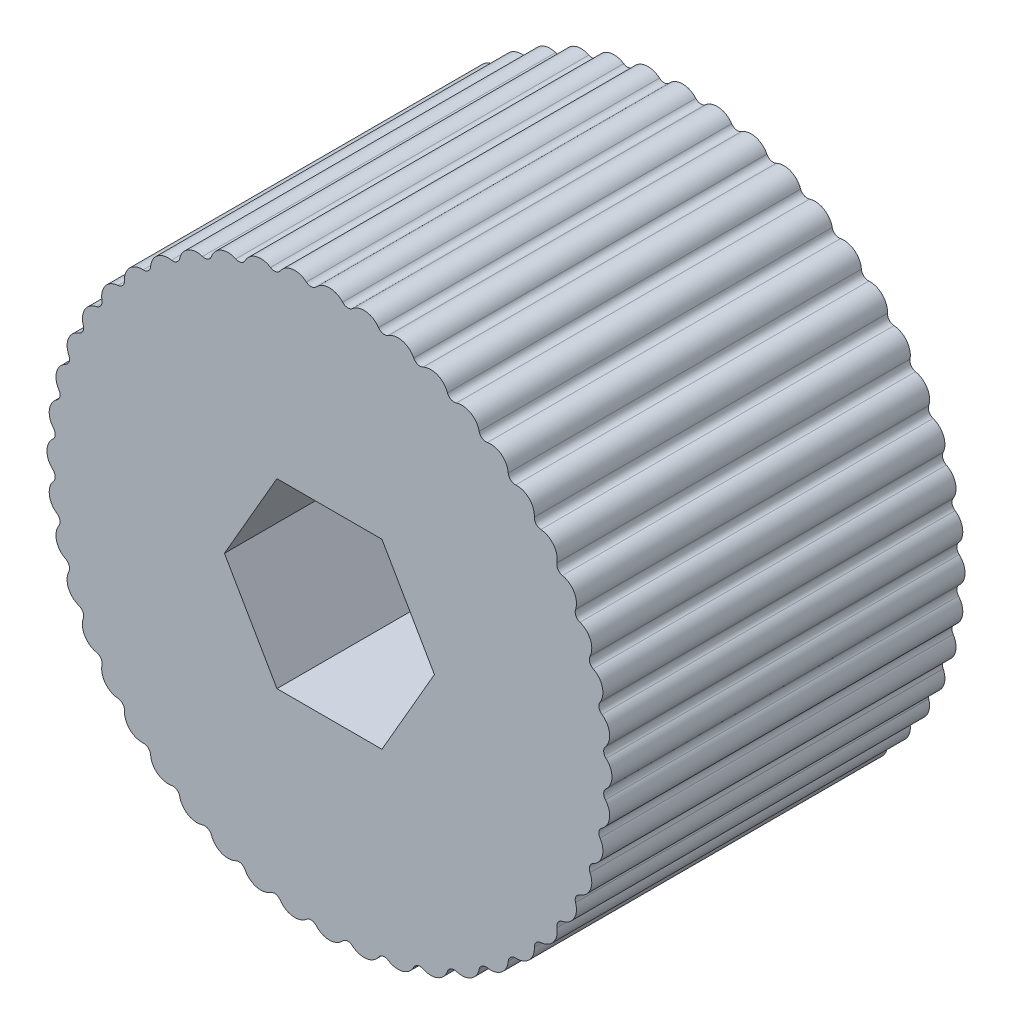
from build123d import *

# Parameters (mm, degrees)
SKETCH1_R           = 19.05
BOSS_EXTRUDE1_DEPTH = 25.4
BOSS_EXTRUDE2_DEPTH = 25.4
CIRPATTERN1_COUNT   = 48
FILLET1_R           = 0.508


with BuildPart() as part:
    # Sketch1 → Boss-Extrude1 (new body)
    with BuildSketch(Plane.XY):
        Circle(SKETCH1_R)
        Polygon((3.776159436, 6.5405), (-3.776159436, 6.5405), (-7.552318871, 0), (-3.776159436, -6.5405), (3.776159436, -6.5405), (7.552318871, 0), align=None, mode=Mode.SUBTRACT)
    extrude(amount=BOSS_EXTRUDE1_DEPTH)

    # Sketch2 → Boss-Extrude2 (add)
    with BuildSketch(Plane.XY.offset(25.4)):
        with BuildLine():
            Line((19.007666667, 1.269294248), (19.007666667, -1.269294248))
            ThreePointArc((19.007666667, -1.269294248), (20.32, 0), (19.007666667, 1.269294248))
        make_face()
    boss_extrude2 = extrude(amount=-BOSS_EXTRUDE2_DEPTH)

    # CirPattern1: Boss-Extrude2 ×48 about axis
    cirpattern1_axis = Axis((0, 0, 0), (0, 0, 1))
    for i in range(1, CIRPATTERN1_COUNT):
        add(boss_extrude2.rotate(cirpattern1_axis, i * 360 / CIRPATTERN1_COUNT))

    # Fillet1
    fillet1_edges = [part.edges().sort_by_distance(p)[0] for p in [
        (18.885315485, 3.756522812, 12.7),
        (18.233424374, 6.189413557, 12.7),
        (17.269554317, 8.516401721, 12.7),
        (16.010197398, 10.69767189, 12.7),
        (14.476901562, 12.695901927, 12.7),
        (12.695901927, 14.476901562, 12.7),
        (10.69767189, 16.010197398, 12.7),
        (8.516401721, 17.269554317, 12.7),
        (6.189413557, 18.233424374, 12.7),
        (3.756522812, 18.885315485, 12.7),
        (1.259356919, 19.214073611, 12.7),
        (-1.259356919, 19.214073611, 12.7),
        (-3.756522812, 18.885315485, 12.7),
        (-6.189413557, 18.233424374, 12.7),
        (-8.516401721, 17.269554317, 12.7),
        (-10.69767189, 16.010197398, 12.7),
        (-12.695901927, 14.476901562, 12.7),
        (-14.476901562, 12.695901927, 12.7),
        (-16.010197398, 10.69767189, 12.7),
        (-17.269554317, 8.516401721, 12.7),
        (-18.233424374, 6.189413557, 12.7),
        (-18.885315485, 3.756522812, 12.7),
        (-19.214073611, 1.259356919, 12.7),
        (-19.214073611, -1.259356919, 12.7),
        (-18.885315485, -3.756522812, 12.7),
        (-18.233424374, -6.189413557, 12.7),
        (-17.269554317, -8.516401721, 12.7),
        (-16.010197398, -10.69767189, 12.7),
        (-14.476901562, -12.695901927, 12.7),
        (-12.695901927, -14.476901562, 12.7),
        (-10.69767189, -16.010197398, 12.7),
        (-8.516401721, -17.269554317, 12.7),
        (-6.189413557, -18.233424374, 12.7),
        (-3.756522812, -18.885315485, 12.7),
        (-1.259356919, -19.214073611, 12.7),
        (1.259356919, -19.214073611, 12.7),
        (3.756522812, -18.885315485, 12.7),
        (6.189413557, -18.233424374, 12.7),
        (8.516401721, -17.269554317, 12.7),
        (10.69767189, -16.010197398, 12.7),
        (12.695901927, -14.476901562, 12.7),
        (14.476901562, -12.695901927, 12.7),
        (16.010197398, -10.69767189, 12.7),
        (17.269554317, -8.516401721, 12.7),
        (18.233424374, -6.189413557, 12.7),
        (18.885315485, -3.756522812, 12.7),
        (19.214073611, -1.259356919, 12.7),
        (19.214073611, 1.259356919, 12.7),
    ]]
    fillet(fillet1_edges, radius=FILLET1_R)


solid = part.part
